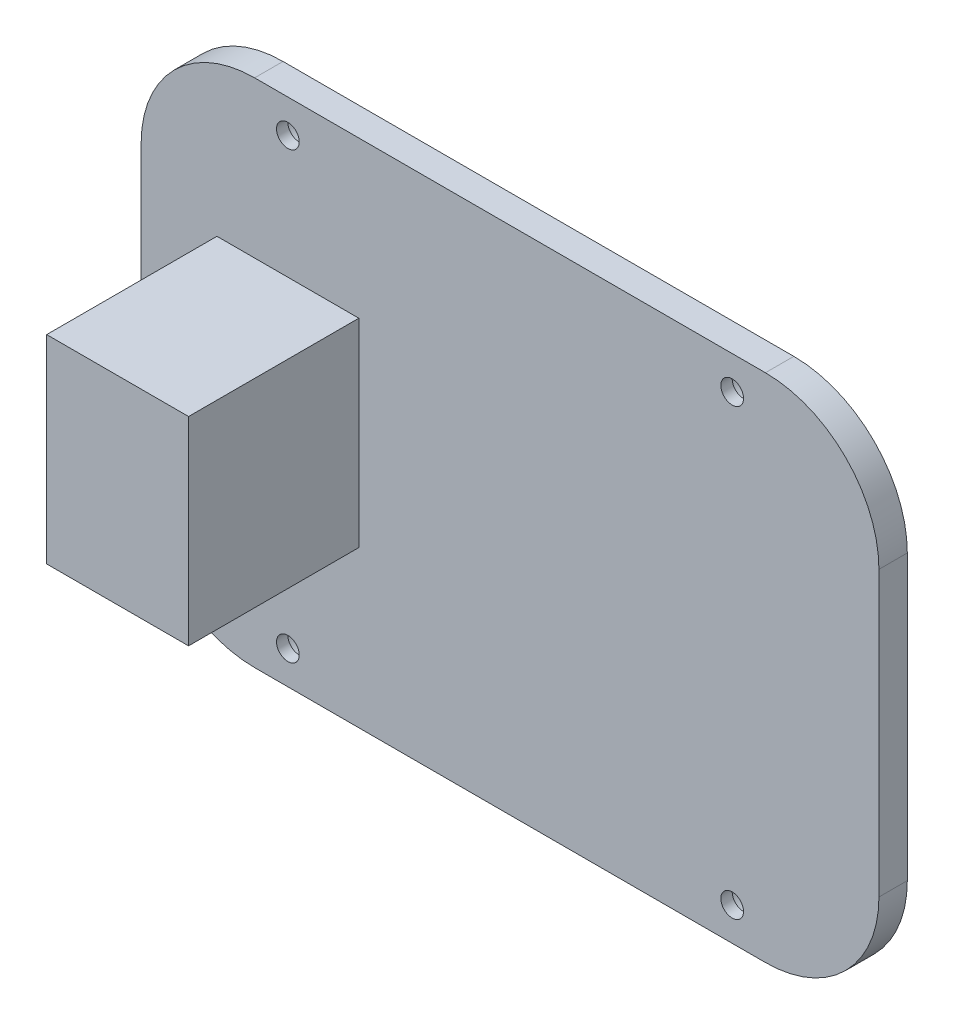
from build123d import *

# Parameters (mm, degrees)
SKETCH1_W           = 130
SKETCH1_H           = 90
BOSS_EXTRUDE1_DEPTH = 5
FILLET1_R           = 20
SKETCH2_R           = 4
CUT_EXTRUDE1_DEPTH  = 3
SKETCH3_R           = 2
CUT_EXTRUDE2_DEPTH  = 6
SKETCH4_W           = 25
SKETCH4_H           = 35
BOSS_EXTRUDE2_DEPTH = 30


with BuildPart() as part:
    # Sketch1 → Boss-Extrude1 (new body)
    with BuildSketch(Plane.XY):
        Rectangle(SKETCH1_W, SKETCH1_H)
    extrude(amount=BOSS_EXTRUDE1_DEPTH)

    # Fillet1
    fillet1_edges = [part.edges().sort_by_distance(p)[0] for p in [
        (65, -45, 2.5),
        (-65, -45, 2.5),
        (-65, 45, 2.5),
        (65, 45, 2.5),
    ]]
    fillet(fillet1_edges, radius=FILLET1_R)

    # Sketch2 → Cut-Extrude1 (cut)
    with BuildSketch(Plane(origin=(0, 0, 0), x_dir=(-1, 0, 0), z_dir=(0, 0, -1))):
        with Locations((-39.142135624, 39.142135624)):
            Circle(SKETCH2_R)
        with Locations((39.142135624, 39.142135624)):
            Circle(SKETCH2_R)
        with Locations((-39.142135624, -39.142135624)):
            Circle(SKETCH2_R)
        with Locations((39.142135624, -39.142135624)):
            Circle(SKETCH2_R)
    extrude(amount=-CUT_EXTRUDE1_DEPTH, mode=Mode.SUBTRACT)

    # Sketch3 → Cut-Extrude2 (cut, through all)
    with BuildSketch(Plane(origin=(0, 0, 0), x_dir=(-1, 0, 0), z_dir=(0, 0, -1))):
        with Locations((-39.142135624, 39.142135624)):
            Circle(SKETCH3_R)
        with Locations((39.142135624, 39.142135624)):
            Circle(SKETCH3_R)
        with Locations((39.142135624, -39.142135624)):
            Circle(SKETCH3_R)
        with Locations((-39.142135624, -39.142135624)):
            Circle(SKETCH3_R)
    extrude(amount=-CUT_EXTRUDE2_DEPTH, mode=Mode.SUBTRACT)

    # Sketch4 → Boss-Extrude2 (add)
    with BuildSketch(Plane.XY.offset(5)):
        with Locations((-39.142135624, 0)):
            Rectangle(SKETCH4_W, SKETCH4_H)
    extrude(amount=BOSS_EXTRUDE2_DEPTH)


solid = part.part
